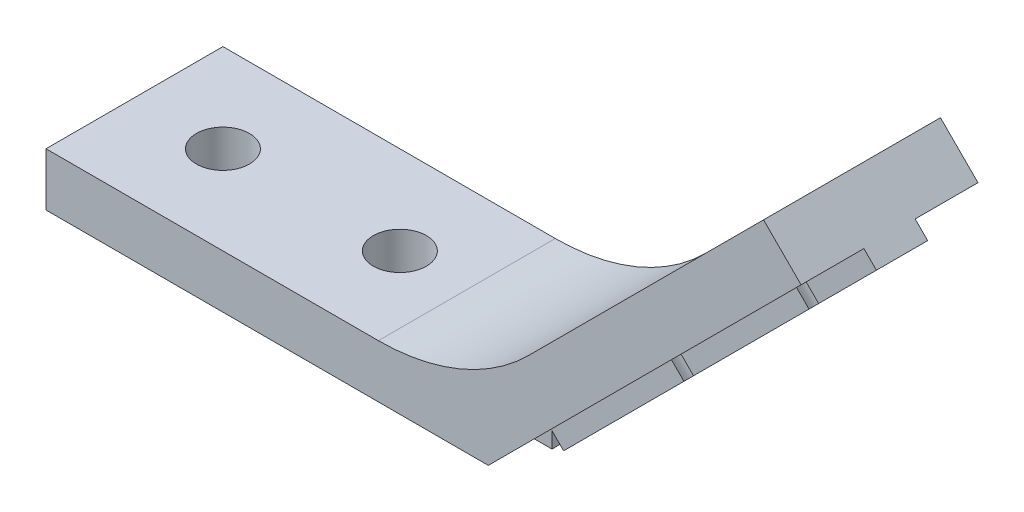
from build123d import *

# Parameters (mm, degrees)
BOSS_EXTRU_1_DEPTH           = 10
ESQUISSE4_W                  = 25
ESQUISSE4_H                  = 2.8
BOSS_EXTRU_2_DEPTH           = 1
ESQUISSE2_R                  = 1.5
ENL_V_MAT_EXTRU_1_DEPTH      = 34.421549934
ENL_V_MAT_EXTRU_1_DEPTH_BACK = 34.421549934
ESQUISSE5_W                  = 2.9
ESQUISSE5_H                  = 25
BOSS_EXTRU_3_DEPTH           = 1
ESQUISSE3_R                  = 1.5
ENL_V_MAT_EXTRU_2_DEPTH      = 34.421549934
ENL_V_MAT_EXTRU_2_DEPTH_BACK = 34.421549934


with BuildPart() as part:
    # Esquisse1 → Boss.-Extru.1 (new body)
    with BuildSketch(Plane.XY):
        with BuildLine():
            Line((-25, 0), (0, 0))
            Line((0, 0), (17.67766953, 17.67766953))
            Line((17.67766953, 17.67766953), (15.556349186, 19.798989873))
            Line((15.556349186, 19.798989873), (2.272077939, 6.514718626))
            ThreePointArc((2.272077939, 6.514718626), (-1.621002247, 3.91344561), (-6.213203436, 3))
            Line((-6.213203436, 3), (-25, 3))
            Line((-25, 3), (-25, 0))
        make_face()
    extrude(amount=BOSS_EXTRU_1_DEPTH)

    # Esquisse4 → Boss.-Extru.2 (add)
    with BuildSketch(Plane(origin=(0, 0, 0), x_dir=(-1, 0, 0), z_dir=(0, -1, 0))):
        with Locations((12.5, -5)):
            Rectangle(ESQUISSE4_W, ESQUISSE4_H)
    extrude(amount=BOSS_EXTRU_2_DEPTH)

    # Esquisse2 → Enlèv. mat.-Extru.1 (cut, two sides)
    with BuildSketch(Plane.XZ) as enl_v_mat_extru_1_sk:
        with Locations(Location((-20, 5, 0), (0, 0, 270))):
            Circle(ESQUISSE2_R)
        with Locations(Location((-10, 5, 0), (0, 0, 270))):
            Circle(ESQUISSE2_R)
    extrude(amount=ENL_V_MAT_EXTRU_1_DEPTH, mode=Mode.SUBTRACT)
    extrude(enl_v_mat_extru_1_sk.sketch, amount=-ENL_V_MAT_EXTRU_1_DEPTH_BACK, mode=Mode.SUBTRACT)

    # Esquisse5 → Boss.-Extru.3 (add)
    with BuildSketch(Plane(origin=(0, 0, 0), x_dir=(0, 0, -1), z_dir=(0.7071067811865485, -0.7071067811865466, 0))):
        with Locations((-5, 12.5)):
            Rectangle(ESQUISSE5_W, ESQUISSE5_H)
    extrude(amount=BOSS_EXTRU_3_DEPTH)

    # Esquisse3 → Enlèv. mat.-Extru.2 (cut, two sides)
    with BuildSketch(Plane(origin=(0, 0, 0), x_dir=(0, 0, -1), z_dir=(0.7071067811865485, -0.7071067811865466, 0))) as enl_v_mat_extru_2_sk:
        with Locations(Location((-5, 10, 0), (0, 0, 90))):
            Circle(ESQUISSE3_R)
        with Locations(Location((-5, 20, 0), (0, 0, 90))):
            Circle(ESQUISSE3_R)
    extrude(amount=ENL_V_MAT_EXTRU_2_DEPTH, mode=Mode.SUBTRACT)
    extrude(enl_v_mat_extru_2_sk.sketch, amount=-ENL_V_MAT_EXTRU_2_DEPTH_BACK, mode=Mode.SUBTRACT)


solid = part.part
